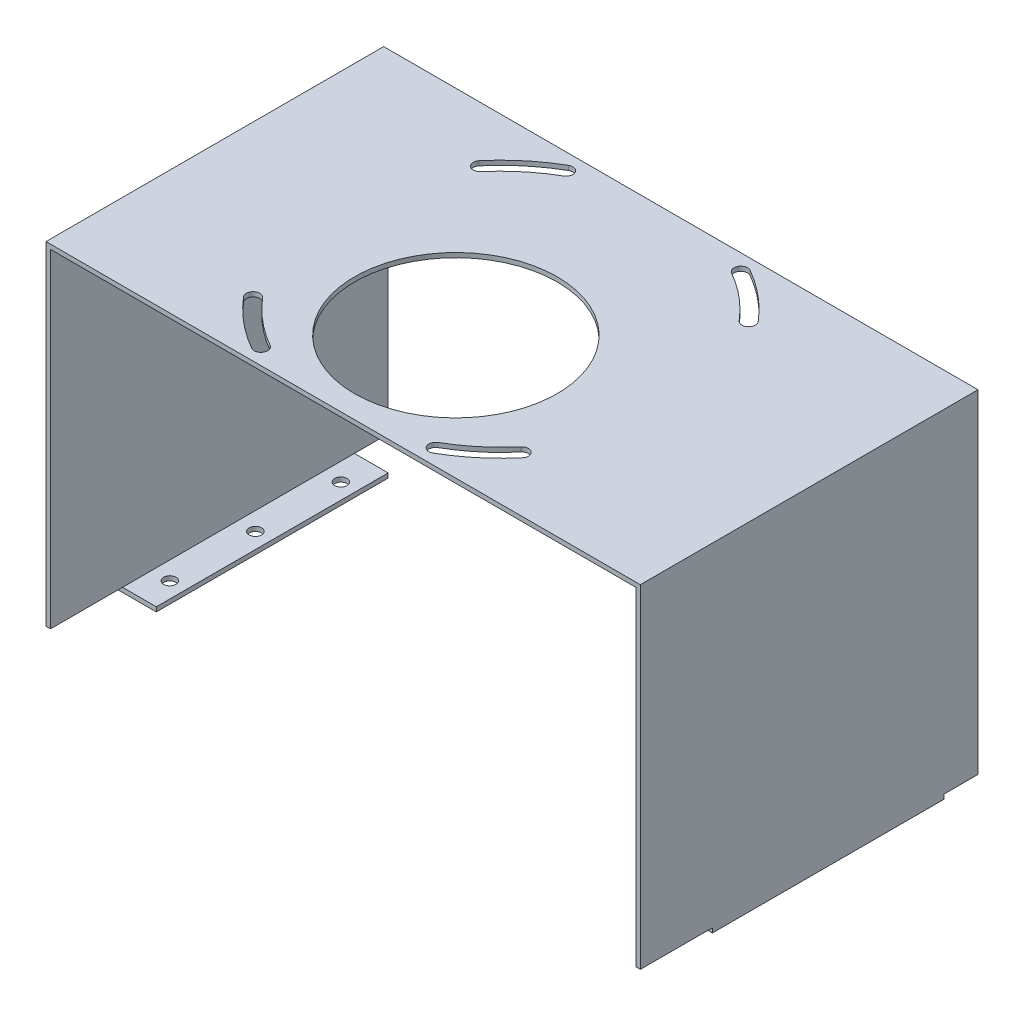
from build123d import *

# Parameters (mm, degrees)
BOSS_EXTRUDE1_DEPTH      = 150
CUT_EXTRUDE1_REACH       = 152
SKETCH3_R                = 45
CUT_EXTRUDE2_DEPTH       = 100
M5_CLEARANCE_HOLE1_D     = 5.5
M5_CLEARANCE_HOLE1_DEPTH = 2
SKETCH7_W                = 32
SKETCH7_H                = 2
SKETCH7_W_2              = 15
CUT_EXTRUDE3_DEPTH       = 265


with BuildPart() as part:
    # Sketch1 → Boss-Extrude1 (new body)
    with BuildSketch(Plane.XY):
        Polygon((0, 0), (0, 150), (264, 150), (264, 0), (247, 0), (247, 2), (262, 2), (262, 148), (2, 148), (2, 2), (17, 2), (17, 0), align=None)
    extrude(amount=-BOSS_EXTRUDE1_DEPTH)

    # Sketch2 → Cut-Extrude1 (cut, up to next)
    with BuildSketch(Plane(origin=(0, 150, 0), x_dir=(1, 0, 0), z_dir=(0, 1, 0)), mode=Mode.PRIVATE) as cut_extrude1_sk1:
        with BuildLine():
            ThreePointArc((86.747328005, 145.374025445), (75.139446801, 137.30466384), (65.109145333, 127.342206552))
            ThreePointArc((65.109145333, 127.342206552), (65.464571436, 123.114479942), (69.692298045, 123.469906045))
            ThreePointArc((69.692298045, 123.469906045), (78.980553199, 132.695336162), (89.729678014, 140.167722686))
            ThreePointArc((89.729678014, 140.167722686), (90.841654389, 144.26204907), (86.747328005, 145.374025445))
        make_face()
    cut_extrude1_tool1 = extrude(cut_extrude1_sk1.sketch, amount=-CUT_EXTRUDE1_REACH, mode=Mode.PRIVATE) & part.part
    add(cut_extrude1_tool1.solids().sort_by_distance((77.388056, 150, -134.606333))[0], mode=Mode.SUBTRACT)
    # Sketch2 → Cut-Extrude1 (cut, up to next)
    with BuildSketch(Plane(origin=(0, 150, 0), x_dir=(1, 0, 0), z_dir=(0, 1, 0)), mode=Mode.PRIVATE) as cut_extrude1_sk2:
        with BuildLine():
            ThreePointArc((164.390321986, 140.167722686), (163.278345611, 144.26204907), (167.372671995, 145.374025445))
            ThreePointArc((167.372671995, 145.374025445), (178.980553199, 137.30466384), (189.010854667, 127.342206552))
            ThreePointArc((189.010854667, 127.342206552), (188.655428564, 123.114479942), (184.427701955, 123.469906045))
            ThreePointArc((184.427701955, 123.469906045), (175.139446801, 132.695336162), (164.390321986, 140.167722686))
        make_face()
    cut_extrude1_tool2 = extrude(cut_extrude1_sk2.sketch, amount=-CUT_EXTRUDE1_REACH, mode=Mode.PRIVATE) & part.part
    add(cut_extrude1_tool2.solids().sort_by_distance((176.731944, 150, -134.606333))[0], mode=Mode.SUBTRACT)
    # Sketch2 → Cut-Extrude1 (cut, up to next)
    with BuildSketch(Plane(origin=(0, 150, 0), x_dir=(1, 0, 0), z_dir=(0, 1, 0)), mode=Mode.PRIVATE) as cut_extrude1_sk3:
        with BuildLine():
            ThreePointArc((167.372671995, 4.625974555), (178.980553199, 12.69533616), (189.010854667, 22.657793448))
            ThreePointArc((189.010854667, 22.657793448), (188.655428564, 26.885520058), (184.427701955, 26.530093955))
            ThreePointArc((184.427701955, 26.530093955), (175.139446801, 17.304663838), (164.390321986, 9.832277314))
            ThreePointArc((164.390321986, 9.832277314), (163.278345611, 5.73795093), (167.372671995, 4.625974555))
        make_face()
    cut_extrude1_tool3 = extrude(cut_extrude1_sk3.sketch, amount=-CUT_EXTRUDE1_REACH, mode=Mode.PRIVATE) & part.part
    add(cut_extrude1_tool3.solids().sort_by_distance((176.731944, 150, -15.393667))[0], mode=Mode.SUBTRACT)
    # Sketch2 → Cut-Extrude1 (cut, up to next)
    with BuildSketch(Plane(origin=(0, 150, 0), x_dir=(1, 0, 0), z_dir=(0, 1, 0)), mode=Mode.PRIVATE) as cut_extrude1_sk4:
        with BuildLine():
            ThreePointArc((89.729678014, 9.832277314), (90.841654389, 5.73795093), (86.747328005, 4.625974555))
            ThreePointArc((86.747328005, 4.625974555), (75.139446801, 12.69533616), (65.109145333, 22.657793448))
            ThreePointArc((65.109145333, 22.657793448), (65.464571436, 26.885520058), (69.692298045, 26.530093955))
            ThreePointArc((69.692298045, 26.530093955), (78.980553199, 17.304663838), (89.729678014, 9.832277314))
        make_face()
    cut_extrude1_tool4 = extrude(cut_extrude1_sk4.sketch, amount=-CUT_EXTRUDE1_REACH, mode=Mode.PRIVATE) & part.part
    add(cut_extrude1_tool4.solids().sort_by_distance((77.388056, 150, -15.393667))[0], mode=Mode.SUBTRACT)

    # Sketch3 → Cut-Extrude2 (cut)
    with BuildSketch(Plane(origin=(0, 150, 0), x_dir=(1, 0, 0), z_dir=(0, 1, 0))):
        with Locations(Location((127.06, 55, 0), (0, 0, 270))):  # turned: the seam where the file's is
            Circle(SKETCH3_R)
    extrude(amount=-CUT_EXTRUDE2_DEPTH, mode=Mode.SUBTRACT)

    # M5 Clearance Hole1
    with Locations(Plane.XZ):
        with Locations((10, -45), (10, -121), (10, -83), (254, -83), (254, -121), (254, -45)):
            Hole(M5_CLEARANCE_HOLE1_D / 2, depth=M5_CLEARANCE_HOLE1_DEPTH)

    # Sketch7 → Cut-Extrude3 (cut, through all)
    with BuildSketch(Plane(origin=(264, 0, 0), x_dir=(0, 0, -1), z_dir=(1, 0, 0))):
        with Locations((16, 1)):
            Rectangle(SKETCH7_W, SKETCH7_H)
        with Locations((142.5, 1)):
            Rectangle(SKETCH7_W_2, SKETCH7_H)
    extrude(amount=-CUT_EXTRUDE3_DEPTH, mode=Mode.SUBTRACT)


solid = part.part
